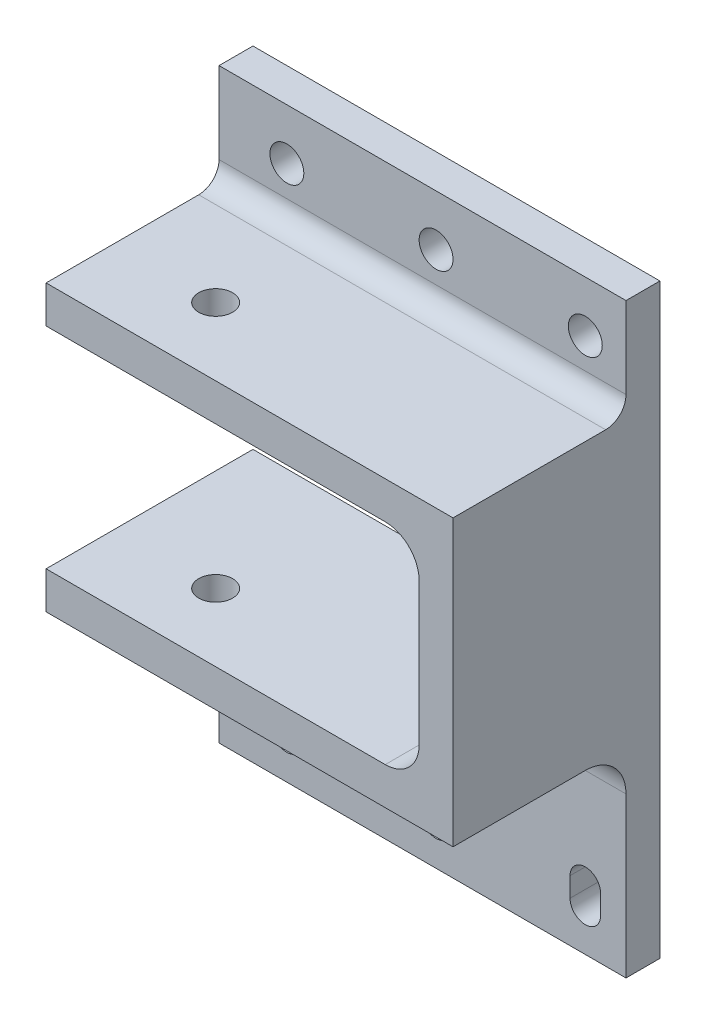
from build123d import *

# Parameters (mm, degrees)
SKETCH2_W           = 65
SKETCH2_H           = 50
EXTRUDE_5_DEPTH     = 42
SKETCH3_W           = 110
SKETCH3_H           = 31
CUT_EXTRUDE1_DEPTH  = 50
SKETCH4_R           = 2.5
CUT_EXTRUDE2_DEPTH  = 50
SKETCH5_W           = 65
SKETCH5_H           = 15
CUT_EXTRUDE3_DEPTH  = 50
SKETCH6_W           = 65
SKETCH6_H           = 4.5
CUT_EXTRUDE4_DEPTH  = 50
SKETCH7_W           = 65
SKETCH7_H           = 35
BOSS_EXTRUDE2_DEPTH = 5
FILLET1_R           = 5
FILLET2_R           = 6
SKETCH8_W           = 65
SKETCH8_H           = 15
BOSS_EXTRUDE3_DEPTH = 5
FILLET3_R           = 3
SKETCH9_R           = 2.5
CUT_EXTRUDE5_DEPTH  = 5
CUT_EXTRUDE6_DEPTH  = 5
SKETCH11_W          = 5
SKETCH11_H          = 86.5
CUT_EXTRUDE8_DEPTH  = 71


with BuildPart() as part:
    # Sketch2 → Extrude 5 (new body)
    with BuildSketch(Plane(origin=(0, 0, 0), x_dir=(1, 0, 0), z_dir=(0, 1, 0))):
        Rectangle(SKETCH2_W, SKETCH2_H)
    extrude(amount=EXTRUDE_5_DEPTH)

    # Sketch3 → Cut-Extrude1 (cut)
    with BuildSketch(Plane.XY.offset(25)):
        with Locations((-32.5, 21)):
            Rectangle(SKETCH3_W, SKETCH3_H)
    extrude(amount=-CUT_EXTRUDE1_DEPTH, mode=Mode.SUBTRACT)

    # Sketch4 → Cut-Extrude2 (cut)
    with BuildSketch(Plane(origin=(0, 42, 0), x_dir=(1, 0, 0), z_dir=(0, 1, 0))):
        with Locations((-17.5, 0)):
            Circle(SKETCH4_R)
    extrude(amount=-CUT_EXTRUDE2_DEPTH, mode=Mode.SUBTRACT)

    # Sketch5 → Cut-Extrude3 (cut)
    with BuildSketch(Plane(origin=(0, 42, 0), x_dir=(1, 0, 0), z_dir=(0, 1, 0))):
        with Locations((0, -17.5)):
            Rectangle(SKETCH5_W, SKETCH5_H)
    extrude(amount=-CUT_EXTRUDE3_DEPTH, mode=Mode.SUBTRACT)

    # Sketch6 → Cut-Extrude4 (cut)
    with BuildSketch(Plane(origin=(0, 42, 0), x_dir=(1, 0, 0), z_dir=(0, 1, 0))):
        with Locations((0, 22.75)):
            Rectangle(SKETCH6_W, SKETCH6_H)
    extrude(amount=-CUT_EXTRUDE4_DEPTH, mode=Mode.SUBTRACT)

    # Sketch7 → Boss-Extrude2 (add)
    with BuildSketch(Plane(origin=(0, 0, -20.5), x_dir=(-1, 0, 0), z_dir=(0, 0, -1))):
        with Locations((0, -12)):
            Rectangle(SKETCH7_W, SKETCH7_H)
    extrude(amount=-BOSS_EXTRUDE2_DEPTH)

    # Fillet1
    fillet1_edges = [part.edges().sort_by_distance(p)[0] for p in [
        (22.5, 5.5, -5.25),
        (22.5, 36.5, -5.25),
    ]]
    fillet(fillet1_edges, radius=FILLET1_R)

    # Fillet2
    fillet2_edges = [part.edges().sort_by_distance(p)[0] for p in [
        (0, 0, -15.5),
    ]]
    fillet(fillet2_edges, radius=FILLET2_R)

    # Sketch8 → Boss-Extrude3 (add)
    with BuildSketch(Plane(origin=(0, 0, -20.5), x_dir=(-1, 0, 0), z_dir=(0, 0, -1))):
        with Locations((0, 49.5)):
            Rectangle(SKETCH8_W, SKETCH8_H)
    extrude(amount=-BOSS_EXTRUDE3_DEPTH)

    # Fillet3
    fillet3_edges = [part.edges().sort_by_distance(p)[0] for p in [
        (0, 42, -15.5),
    ]]
    fillet(fillet3_edges, radius=FILLET3_R)

    # Sketch9 → Cut-Extrude5 (cut)
    with BuildSketch(Plane.XY.offset(-15.5)):
        with Locations((-22.5, 49.5)):
            Circle(SKETCH9_R)
        with Locations((-0.5, 49.5)):
            Circle(SKETCH9_R)
        with Locations((21.5, 49.5)):
            Circle(SKETCH9_R)
    extrude(amount=-CUT_EXTRUDE5_DEPTH, mode=Mode.SUBTRACT)

    # Sketch10 → Cut-Extrude6 (cut)
    with BuildSketch(Plane.XY.offset(-15.5)):
        with BuildLine():
            Line((-24.75, -23.440008753), (-24.75, -20.559991247))
            ThreePointArc((-24.75, -20.559991247), (-22.5, -18.309991247), (-20.25, -20.559991247))
            Line((-20.25, -20.559991247), (-20.25, -23.440008753))
            ThreePointArc((-20.25, -23.440008753), (-22.5, -25.690008753), (-24.75, -23.440008753))
        make_face()
        with BuildLine():
            Line((-2.75, -23.440008753), (-2.75, -20.559991247))
            ThreePointArc((-2.75, -20.559991247), (-0.5, -18.309991247), (1.75, -20.559991247))
            Line((1.75, -20.559991247), (1.75, -23.440008753))
            ThreePointArc((1.75, -23.440008753), (-0.5, -25.690008753), (-2.75, -23.440008753))
        make_face()
        with BuildLine():
            Line((19.25, -23.440008753), (19.25, -20.559991247))
            ThreePointArc((19.25, -20.559991247), (21.5, -18.309991247), (23.75, -20.559991247))
            Line((23.75, -20.559991247), (23.75, -23.440008753))
            ThreePointArc((23.75, -23.440008753), (21.5, -25.690008753), (19.25, -23.440008753))
        make_face()
    extrude(amount=-CUT_EXTRUDE6_DEPTH, mode=Mode.SUBTRACT)

    # Sketch11 → Cut-Extrude8 (cut)
    with BuildSketch(Plane.XY.offset(10)):
        with Locations((30, 13.75)):
            Rectangle(SKETCH11_W, SKETCH11_H)
    extrude(amount=-CUT_EXTRUDE8_DEPTH, mode=Mode.SUBTRACT)


solid = part.part
